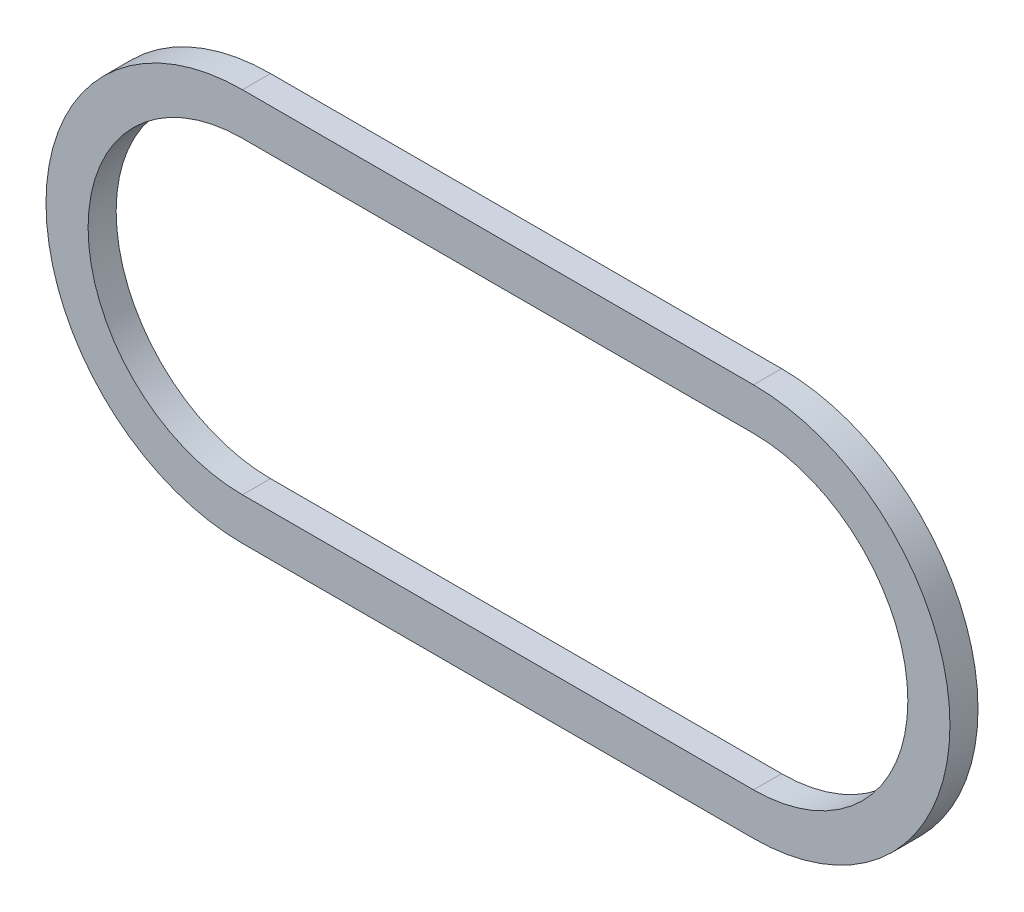
from build123d import *

# Parameters (mm, degrees)
BOSS_EXTRUDE1_DEPTH = 2


with BuildPart() as part:
    # Sketch1 → Boss-Extrude1 (new body)
    with BuildSketch(Plane.XY):
        with BuildLine():
            Line((-18.21, 14), (18.21, 14))
            ThreePointArc((18.21, 14), (32.21, 0), (18.21, -14))
            Line((18.21, -14), (-18.21, -14))
            ThreePointArc((-18.21, -14), (-32.21, 0), (-18.21, 14))
        make_face()
        with BuildLine():
            Line((-18.21, 11), (18.21, 11))
            ThreePointArc((18.21, 11), (29.21, 0), (18.21, -11))
            Line((18.21, -11), (-18.21, -11))
            ThreePointArc((-18.21, -11), (-29.21, 0), (-18.21, 11))
        make_face(mode=Mode.SUBTRACT)
    extrude(amount=BOSS_EXTRUDE1_DEPTH)


solid = part.part
